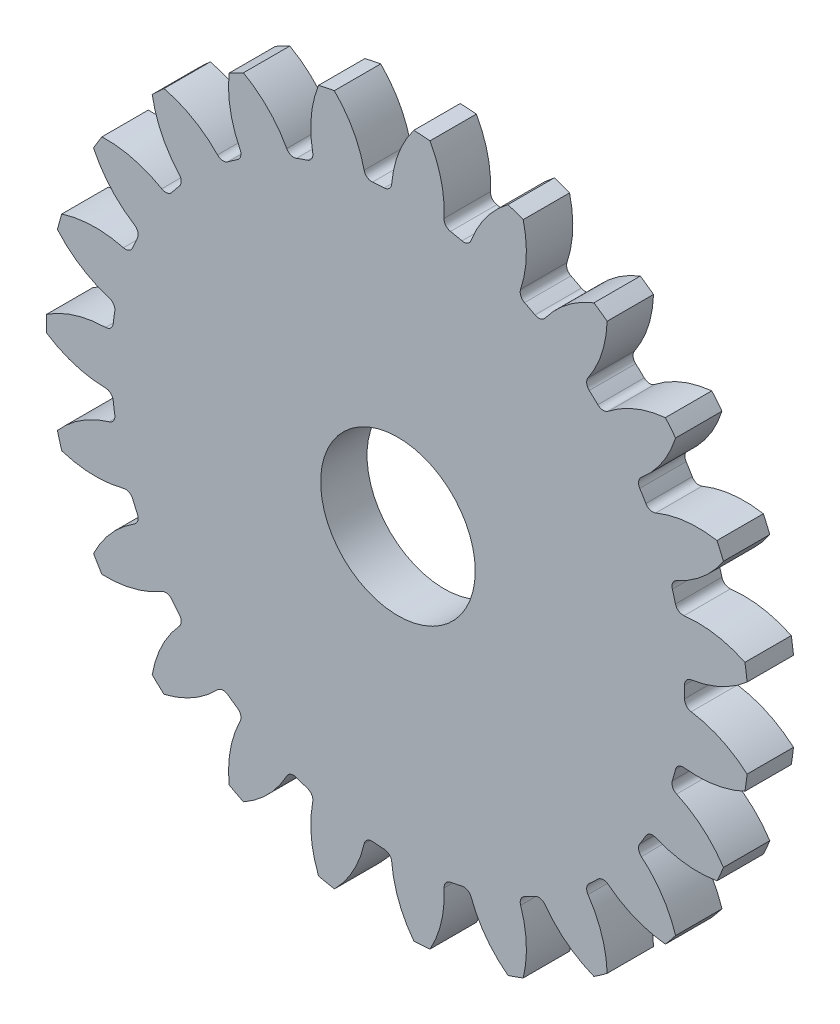
from build123d import *

# Parameters (mm, degrees)
CROQUIS1_R              = 22.733
SALIENTE_EXTRUIR1_DEPTH = 3
CORTAR_EXTRUIR1_DEPTH   = 4
REDONDEO1_R             = 0.508
MATRIZC1_COUNT          = 23
REDONDEO1_OF_MATRIZC1_R = 0.508
CROQUIS3_R              = 5
CORTAR_EXTRUIR2_DEPTH   = 4.0000001


with BuildPart() as part:
    # Croquis1 → Saliente-Extruir1 (new body)
    with BuildSketch(Plane.XY):
        Circle(CROQUIS1_R)
    extrude(amount=SALIENTE_EXTRUIR1_DEPTH)

    # Croquis2 → Cortar-Extruir1 (cut, through all)
    with BuildSketch(Plane.XY.offset(3)):
        with BuildLine():
            ThreePointArc((1.028368398, 22.709728035), (-1.552497561, 22.679925933), (-4.113350795, 22.357764518))
            ThreePointArc((-4.113350795, 22.357764518), (-2.794697294, 20.550064695), (-2.101853062, 18.422485655))
            ThreePointArc((-2.101853062, 18.422485655), (-1.266282927, 18.498710537), (-0.42811991, 18.537056868))
            ThreePointArc((-0.42811991, 18.537056868), (-0.031656093, 20.739201765), (1.028368398, 22.709728035))
        make_face()
    cortar_extruir1 = extrude(amount=-CORTAR_EXTRUIR1_DEPTH, mode=Mode.SUBTRACT)

    # Redondeo1
    redondeo1_edges = [part.edges().sort_by_distance(p)[0] for p in [
        (-0.42811991, 18.537056868, 1.5),
        (-2.101853062, 18.422485655, 1.5),
    ]]
    fillet(redondeo1_edges, radius=REDONDEO1_R)

    # MatrizC1: Cortar-Extruir1 ×23 about axis
    matrizc1_axis = Axis((0, 0, 0), (0, 0, 1))
    for i in range(1, MATRIZC1_COUNT):
        add(cortar_extruir1.rotate(matrizc1_axis, i * 360 / MATRIZC1_COUNT), mode=Mode.SUBTRACT)

    # Redondeo1 of MatrizC1
    redondeo1_of_matrizc1_edges = [part.edges().sort_by_distance(p)[0] for p in [
        (-5.413482153, 17.734147146, 1.5),
        (-6.994237795, 17.172256744, 1.5),
        (-9.997351189, 15.615976857, 1.5),
        (-11.367891908, 14.648440107, 1.5),
        (-13.839762422, 12.339641004, 1.5),
        (-14.898441482, 11.038215681, 1.5),
        (-16.655741789, 8.148130427, 1.5),
        (-17.324041807, 6.609337293, 1.5),
        (-18.236440982, 3.352310292, 1.5),
        (-18.464797204, 1.690274594, 1.5),
        (-18.464626774, -1.692135362, 1.5),
        (-18.236103063, -3.354148038, 1.5),
        (-17.323375669, -6.611083076, 1.5),
        (-16.654920583, -8.149808855, 1.5),
        (-14.897329039, -11.039717003, 1.5),
        (-13.838518834, -12.341035633, 1.5),
        (-11.366415665, -14.649585623, 1.5),
        (-9.99577745, -15.616984253, 1.5),
        (-6.992507239, -17.172961495, 1.5),
        (-5.41169498, -17.734692595, 1.5),
        (-2.099996539, -18.422697374, 1.5),
        (-0.426251851, -18.537099918, 1.5),
        (2.948261296, -18.306106067, 1.5),
        (4.590804429, -17.964695341, 1.5),
        (7.777860079, -16.831834617, 1.5),
        (9.267381745, -16.059931494, 1.5),
        (12.030610561, -14.109222995, 1.5),
        (13.256639753, -12.964075997, 1.5),
        (15.391105694, -10.340194848, 1.5),
        (16.262713435, -8.906734291, 1.5),
        (17.610112928, -5.804281753, 1.5),
        (18.062656059, -4.188820847, 1.5),
        (18.523058646, -0.837891633, 1.5),
        (18.522974114, 0.839758276, 1.5),
        (18.062233842, 4.190641076, 1.5),
        (17.609527916, 5.806056369, 1.5),
        (16.261815783, 8.908373108, 1.5),
        (15.390063591, 10.341745823, 1.5),
        (13.255333241, 12.965411859, 1.5),
        (12.029188654, 14.110435299, 1.5),
        (9.265763271, 16.060865326, 1.5),
        (7.776163825, 16.83261834, 1.5),
        (4.588994027, 17.965157885, 1.5),
        (2.946416498, 18.306403083, 1.5),
    ]]
    fillet(redondeo1_of_matrizc1_edges, radius=REDONDEO1_OF_MATRIZC1_R)

    # Croquis3 → Cortar-Extruir2 (cut, through all)
    with BuildSketch(Plane.XY.offset(3)):
        Circle(CROQUIS3_R)
    extrude(amount=-CORTAR_EXTRUIR2_DEPTH, mode=Mode.SUBTRACT)


solid = part.part
